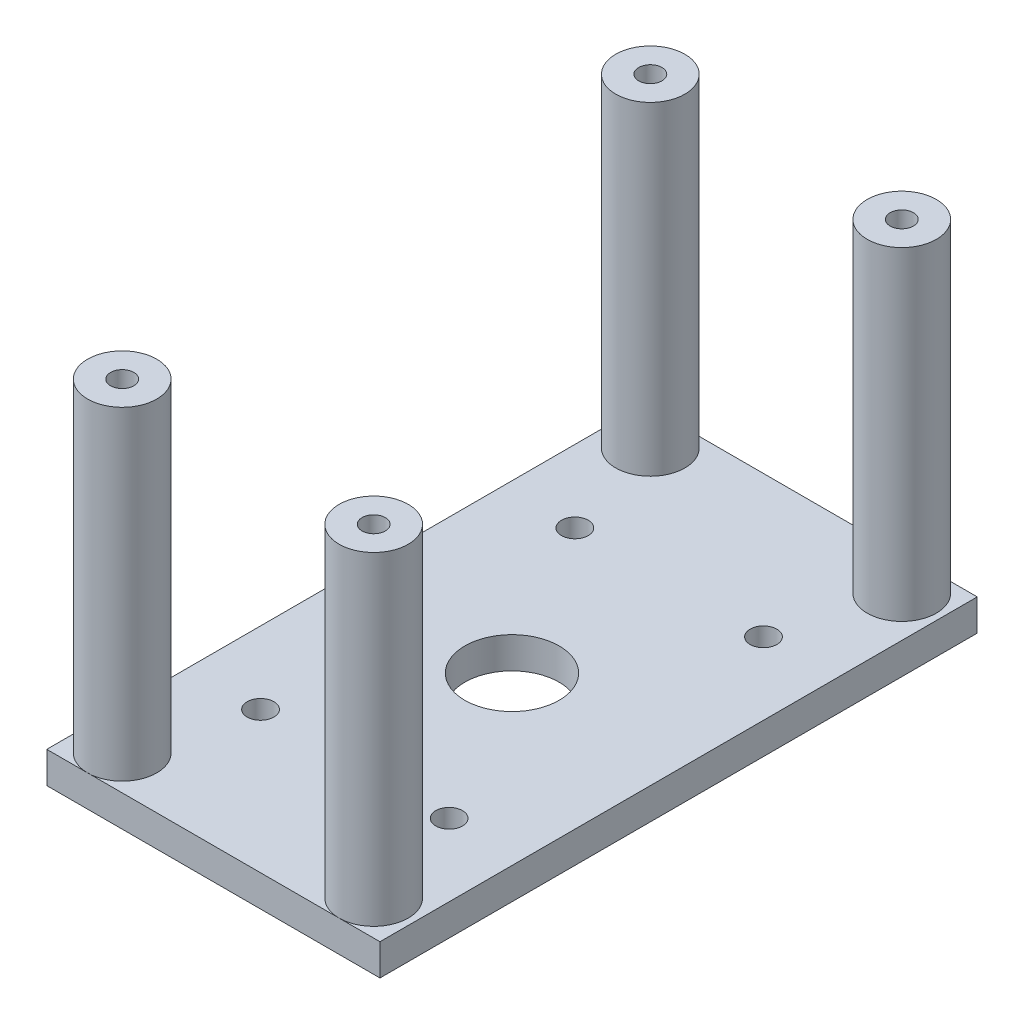
from build123d import *

# Parameters (mm, degrees)
SKETCH1_W           = 53
SKETCH1_H           = 95
BOSS_EXTRUDE1_DEPTH = 5
SKETCH2_R           = 5.5
SKETCH2_R_2         = 1.85
BOSS_EXTRUDE2_DEPTH = 51.5
SKETCH4_R           = 7.5
SKETCH4_R_2         = 2.125
CUT_EXTRUDE1_DEPTH  = 6


with BuildPart() as part:
    # Sketch1 → Boss-Extrude1 (new body)
    with BuildSketch(Plane(origin=(0, 0, 0), x_dir=(1, 0, 0), z_dir=(0, 1, 0))):
        with Locations((26.5, 47.5)):
            Rectangle(SKETCH1_W, SKETCH1_H)
    extrude(amount=BOSS_EXTRUDE1_DEPTH)

    # Sketch2 → Boss-Extrude2 (add)
    with BuildSketch(Plane(origin=(0, 5, 0), x_dir=(1, 0, 0), z_dir=(0, 1, 0))):
        with Locations((46.5, 89.5)):
            Circle(SKETCH2_R)
        with Locations((46.5, 89.5)):
            Circle(SKETCH2_R_2, mode=Mode.SUBTRACT)
        with Locations((6.5, 89.5)):
            Circle(SKETCH2_R)
        with Locations((6.5, 89.5)):
            Circle(SKETCH2_R_2, mode=Mode.SUBTRACT)
        with Locations((6.5, 5.5)):
            Circle(SKETCH2_R)
        with Locations((6.5, 5.5)):
            Circle(SKETCH2_R_2, mode=Mode.SUBTRACT)
        with Locations((46.5, 5.5)):
            Circle(SKETCH2_R)
        with Locations((46.5, 5.5)):
            Circle(SKETCH2_R_2, mode=Mode.SUBTRACT)
    extrude(amount=BOSS_EXTRUDE2_DEPTH)

    # Sketch4 → Cut-Extrude1 (cut, through all)
    with BuildSketch(Plane(origin=(0, 5, 0), x_dir=(1, 0, 0), z_dir=(0, 1, 0))):
        with Locations((26.5, 47.5)):
            Circle(SKETCH4_R)
        with Locations((11.5, 72.5)):
            Circle(SKETCH4_R_2)
        with Locations((41.5, 72.5)):
            Circle(SKETCH4_R_2)
        with Locations((11.5, 22.5)):
            Circle(SKETCH4_R_2)
        with Locations((41.5, 22.5)):
            Circle(SKETCH4_R_2)
    extrude(amount=-CUT_EXTRUDE1_DEPTH, mode=Mode.SUBTRACT)


solid = part.part
